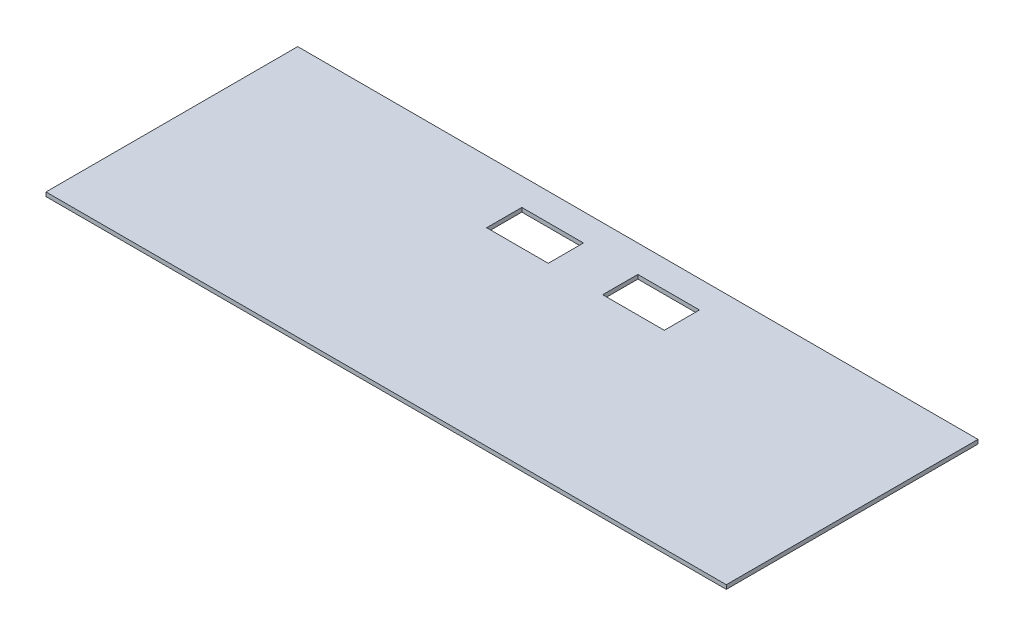
from build123d import *

# Parameters (mm, degrees)
SKETCH1_W           = 500
SKETCH1_H           = 185
BOSS_EXTRUDE1_DEPTH = 3
SKETCH2_W           = 45.28
SKETCH2_H           = 25.85
CUT_EXTRUDE1_DEPTH  = 3


with BuildPart() as part:
    # Sketch1 → Boss-Extrude1 (new body)
    with BuildSketch(Plane(origin=(0, 0, 0), x_dir=(1, 0, 0), z_dir=(0, 1, 0))):
        with Locations((0, -2.5)):
            Rectangle(SKETCH1_W, SKETCH1_H)
    extrude(amount=BOSS_EXTRUDE1_DEPTH)

    # Sketch2 → Cut-Extrude1 (cut)
    with BuildSketch(Plane(origin=(0, 3, 0), x_dir=(1, 0, 0), z_dir=(0, 1, 0))):
        with Locations((-42.64, 57.075)):
            Rectangle(SKETCH2_W, SKETCH2_H)
        with Locations((42.64, 57.075)):
            Rectangle(SKETCH2_W, SKETCH2_H)
    extrude(amount=-CUT_EXTRUDE1_DEPTH, mode=Mode.SUBTRACT)


solid = part.part
